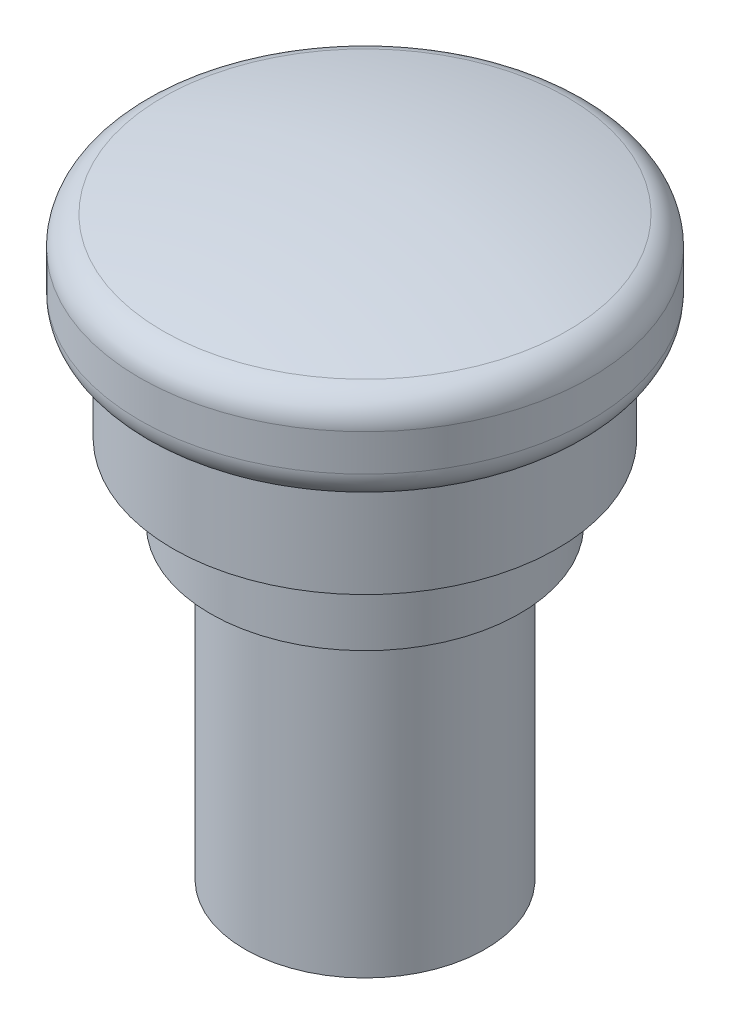
from build123d import *

# Parameters (mm, degrees)
SKETCH1_R           = 8
BOSS_EXTRUDE1_DEPTH = 20.5
SKETCH2_R           = 10.3
BOSS_EXTRUDE2_DEPTH = 4
SKETCH3_R           = 10.9
BOSS_EXTRUDE3_DEPTH = 1
SKETCH4_R           = 12.8
BOSS_EXTRUDE4_DEPTH = 6.5
FILLET1_R           = 2


with BuildPart() as part:
    # Sketch1 → Boss-Extrude1 (new body)
    with BuildSketch(Plane(origin=(0, 0, 0), x_dir=(1, 0, 0), z_dir=(0, 1, 0))):
        Circle(SKETCH1_R)
    extrude(amount=BOSS_EXTRUDE1_DEPTH)

    # Sketch2 → Boss-Extrude2 (add)
    with BuildSketch(Plane(origin=(0, 20.5, 0), x_dir=(1, 0, 0), z_dir=(0, 1, 0))):
        Circle(SKETCH2_R)
    extrude(amount=BOSS_EXTRUDE2_DEPTH)

    # Sketch3 → Boss-Extrude3 (add)
    with BuildSketch(Plane(origin=(0, 24.5, 0), x_dir=(1, 0, 0), z_dir=(0, 1, 0))):
        Circle(SKETCH3_R)
    extrude(amount=BOSS_EXTRUDE3_DEPTH)

    # Sketch4 → Boss-Extrude4 (add)
    with BuildSketch(Plane(origin=(0, 25.5, 0), x_dir=(1, 0, 0), z_dir=(0, 1, 0))):
        Circle(SKETCH4_R)
    extrude(amount=BOSS_EXTRUDE4_DEPTH)

    # Sketch5 → Revolve1 (revolve)
    with BuildSketch(Plane(origin=(0, 0, 0), x_dir=(0, 0, -1), z_dir=(1, 0, 0))):
        with BuildLine():
            Line((0, 32), (0, 40))
            ThreePointArc((0, 40), (-7.566372975, 39.497797314), (-15, 38))
            Line((-15, 38), (-15, 32))
            Line((-15, 32), (-12.8, 32))
            Line((-12.8, 32), (0, 32))
        make_face()
    revolve(axis=Axis((0, 32, 0), (0, 1, 0)))

    # Fillet1
    fillet1_edges = [part.edges().sort_by_distance(p)[0] for p in [
        (0, 38, -15),
        (0, 32, -15),
    ]]
    fillet(fillet1_edges, radius=FILLET1_R)


solid = part.part
